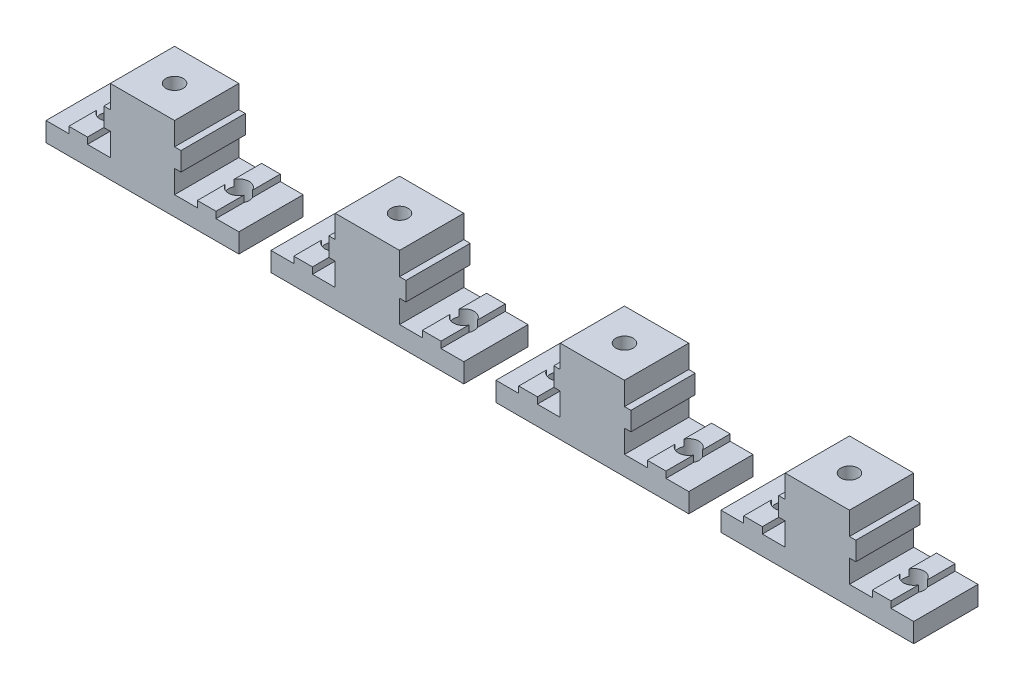
from build123d import *

# Parameters (mm, degrees)
MAIN_DEPTH                 = 10
ESQUISSE2_R                = 1.6
TOPHOLE_DEPTH              = 21.14944168
ESQUISSE3_R                = 1.35
ENL_V_MAT_EXTRU_2_DEPTH    = 23.226110771
R_P_TITION_LIN_AIRE3_COUNT = 4
R_P_TITION_LIN_AIRE3_PITCH = 35


with BuildPart() as part:
    # Esquisse1 → Main (new body)
    with BuildSketch(Plane.XY):
        Polygon((-15, 0), (-15, 3), (-11.45, 3), (-11.45, 4), (-8.55, 4), (-8.55, 3), (-5, 3), (-5, 6.55), (-6, 6.55), (-6, 9.45), (-5, 9.45), (-5, 13), (0, 13), (0, 0), align=None)
    main = extrude(amount=MAIN_DEPTH)

    # Esquisse2 → TopHole (cut, through all)
    with BuildSketch(Plane(origin=(0, 4, 0), x_dir=(1, 0, 0), z_dir=(0, 1, 0))):
        with Locations((-10, -5)):
            Circle(ESQUISSE2_R)
    tophole = extrude(amount=-TOPHOLE_DEPTH, mode=Mode.SUBTRACT)

    # Symétrie1: Main, TopHole across plane
    add(main.mirror(Plane(origin=(0, 0, 0), x_dir=(0, 0, 1), z_dir=(1, 0, 0))))
    add(tophole.mirror(Plane(origin=(0, 0, 0), x_dir=(0, 0, 1), z_dir=(1, 0, 0))), mode=Mode.SUBTRACT)

    # Esquisse3 → Enlèv. mat.-Extru.2 (cut, through all)
    with BuildSketch(Plane(origin=(0, 13, 0), x_dir=(1, 0, 0), z_dir=(0, 1, 0))):
        with Locations((0, -5)):
            Circle(ESQUISSE3_R)
    extrude(amount=-ENL_V_MAT_EXTRU_2_DEPTH, mode=Mode.SUBTRACT)


with BuildPart() as r_p_tition_lin_aire3_1:
    # Répétition linéaire3: pattern copy
    add(part.part.moved(Location(Vector(1, 0, 0) * (1 * R_P_TITION_LIN_AIRE3_PITCH))))


with BuildPart() as r_p_tition_lin_aire3_2:
    # Répétition linéaire3: pattern copy
    add(part.part.moved(Location(Vector(1, 0, 0) * (2 * R_P_TITION_LIN_AIRE3_PITCH))))


with BuildPart() as r_p_tition_lin_aire3_3:
    # Répétition linéaire3: pattern copy
    add(part.part.moved(Location(Vector(1, 0, 0) * (3 * R_P_TITION_LIN_AIRE3_PITCH))))


solid = Compound([part.part, r_p_tition_lin_aire3_1.part, r_p_tition_lin_aire3_2.part, r_p_tition_lin_aire3_3.part])
